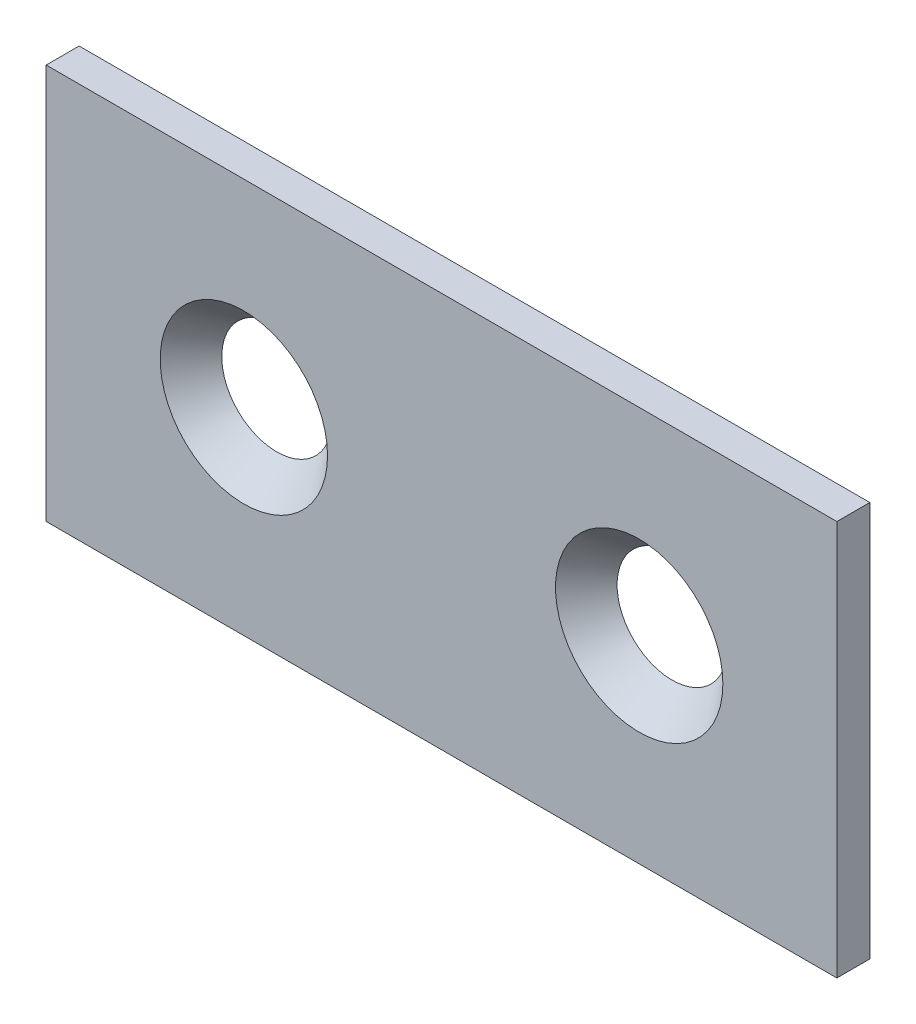
from build123d import *

# Parameters (mm, degrees)
SKETCH1_W                                         = 76.2
SKETCH1_H                                         = 38.1
SKETCH1_R                                         = 4.191
SKETCH1_R_2                                       = 4.1656
BOSS_EXTRUDE1_DEPTH                               = 3.175
CSK_FOR_5_16_FLAT_HEAD_MACHINE_SCREW2_D           = 8.4328
CSK_FOR_5_16_FLAT_HEAD_MACHINE_SCREW2_DEPTH       = 32.766
CSK_FOR_5_16_FLAT_HEAD_MACHINE_SCREW2_CSINK_D     = 16.129
CSK_FOR_5_16_FLAT_HEAD_MACHINE_SCREW2_CSINK_ANGLE = 82
CSK_FOR_5_16_FLAT_HEAD_MACHINE_SCREW2_TIP         = 2.533468714


with BuildPart() as part:
    # Sketch1 → Boss-Extrude1 (new body)
    with BuildSketch(Plane.XY):
        Rectangle(SKETCH1_W, SKETCH1_H)
        with Locations((-19.05, 0)):
            Circle(SKETCH1_R, mode=Mode.SUBTRACT)
        with Locations((19.05, 0)):
            Circle(SKETCH1_R_2, mode=Mode.SUBTRACT)
    extrude(amount=-BOSS_EXTRUDE1_DEPTH)

    # CSK for 5/16 Flat Head Machine Screw2
    with Locations(Plane(origin=(-19.05, 0, 0), x_dir=(1, 0, 0), z_dir=(0, 0, 1))):
        with Locations((0, 0), (38.1, 0)):
            CounterSinkHole(CSK_FOR_5_16_FLAT_HEAD_MACHINE_SCREW2_D / 2, CSK_FOR_5_16_FLAT_HEAD_MACHINE_SCREW2_CSINK_D / 2, depth=CSK_FOR_5_16_FLAT_HEAD_MACHINE_SCREW2_DEPTH, counter_sink_angle=CSK_FOR_5_16_FLAT_HEAD_MACHINE_SCREW2_CSINK_ANGLE)
            with Locations((0, 0, -(CSK_FOR_5_16_FLAT_HEAD_MACHINE_SCREW2_DEPTH + CSK_FOR_5_16_FLAT_HEAD_MACHINE_SCREW2_TIP / 2))):  # 118° drill point
                Cone(0, CSK_FOR_5_16_FLAT_HEAD_MACHINE_SCREW2_D / 2, CSK_FOR_5_16_FLAT_HEAD_MACHINE_SCREW2_TIP, mode=Mode.SUBTRACT)


solid = part.part
